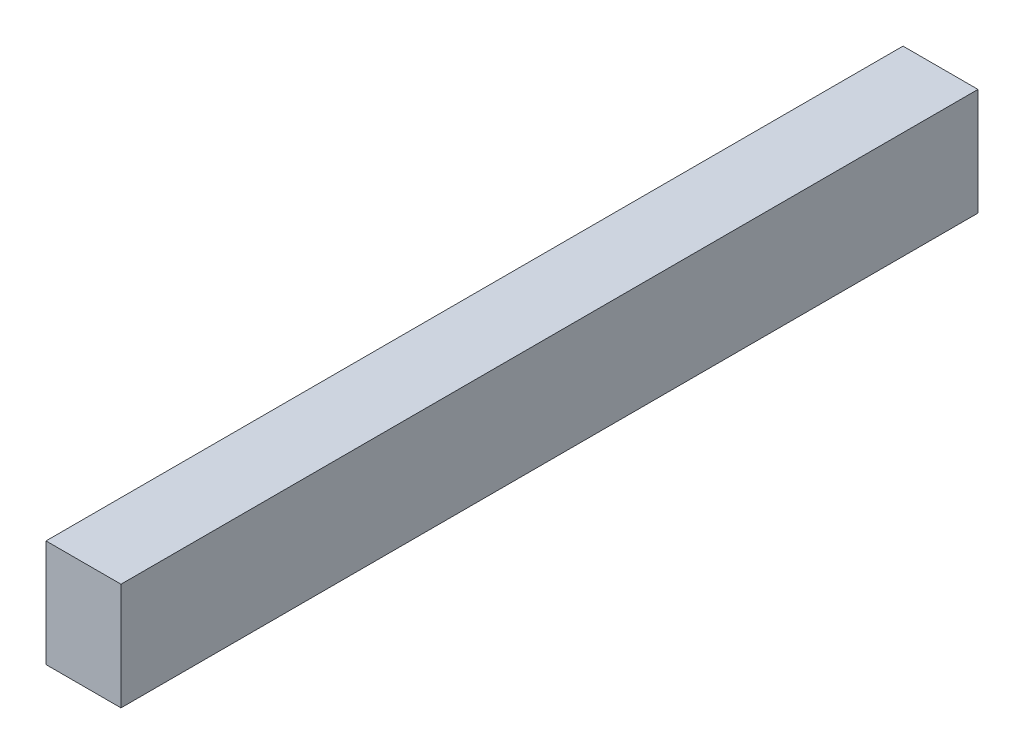
from build123d import *

# Parameters (mm, degrees)
SKETCH1_W           = 7
SKETCH1_H           = 10
BOSS_EXTRUDE1_DEPTH = 80


with BuildPart() as part:
    # Sketch1 → Boss-Extrude1 (new body)
    with BuildSketch(Plane.XY):
        with Locations((3.5, 5)):
            Rectangle(SKETCH1_W, SKETCH1_H)
    extrude(amount=BOSS_EXTRUDE1_DEPTH)


solid = part.part
